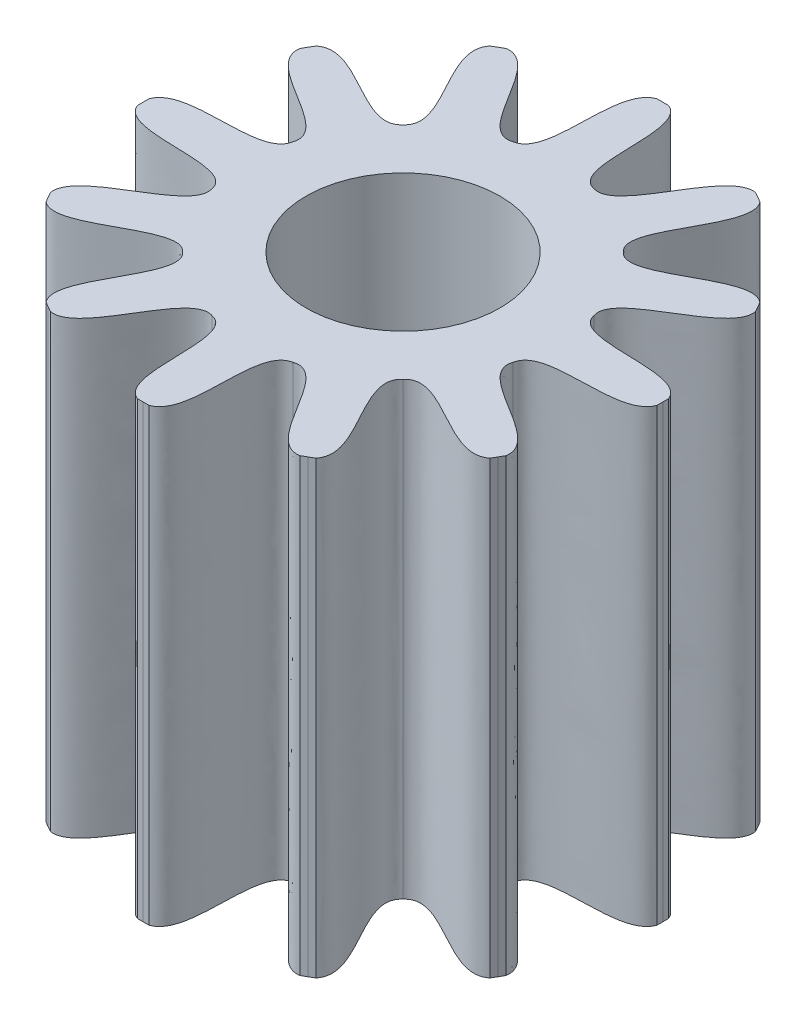
from build123d import *

# Parameters (mm, degrees)
BOSS_EXTRUDE1_12_TEETH_DEPTH = 1.3
CUT_EXTRUDE1_REACH           = 3.3
SKETCH2_R                    = 0.28


with BuildPart() as part:
    # Sketch1 → Boss-Extrude1 (12 teeth) (new body)
    with BuildSketch(Plane(origin=(0, 0, 0), x_dir=(1, 0, 0), z_dir=(0, 1, 0))):
        with BuildLine():
            Line((0, 0.75), (0.016998908, 0.749807333))
            add(Edge.make_bspline(
                [(0.016998908, 0.749807333), (0.1073915, 0.715734638), (0.02468594, 0.452106326), (0.11646857, 0.434666622)],
                knots=[0, 0, 0, 0, 1, 1, 1, 1], degree=3))
            add(Edge.make_bspline(
                [(0.36018218, 0.657851653), (0.264863552, 0.673540129), (0.204674512, 0.403878534), (0.11646857, 0.434666622)],
                knots=[0, 0, 0, 0, 1, 1, 1, 1], degree=3))
            Line((0.36018218, 0.657851653), (0.375, 0.649519053))
            Line((0.375, 0.649519053), (0.389625153, 0.640852745))
            add(Edge.make_bspline(
                [(0.389625153, 0.640852745), (0.450871086, 0.566148629), (0.247431814, 0.379192594), (0.318198052, 0.318198052)],
                knots=[0, 0, 0, 0, 1, 1, 1, 1], degree=3))
            add(Edge.make_bspline(
                [(0.640852745, 0.389625153), (0.566148629, 0.450871086), (0.379192594, 0.247431814), (0.318198052, 0.318198052)],
                knots=[0, 0, 0, 0, 1, 1, 1, 1], degree=3))
            Line((0.640852745, 0.389625153), (0.649519053, 0.375))
            Line((0.649519053, 0.375), (0.657851653, 0.36018218))
            add(Edge.make_bspline(
                [(0.657851653, 0.36018218), (0.673540129, 0.264863552), (0.403878534, 0.204674512), (0.434666622, 0.11646857)],
                knots=[0, 0, 0, 0, 1, 1, 1, 1], degree=3))
            add(Edge.make_bspline(
                [(0.749807333, 0.016998908), (0.715734638, 0.1073915), (0.452106326, 0.02468594), (0.434666622, 0.11646857)],
                knots=[0, 0, 0, 0, 1, 1, 1, 1], degree=3))
            Line((0.749807333, 0.016998908), (0.75, 0))
            Line((0.75, 0), (0.749807333, -0.016998908))
            add(Edge.make_bspline(
                [(0.749807333, -0.016998908), (0.715734638, -0.1073915), (0.452106326, -0.02468594), (0.434666622, -0.11646857)],
                knots=[0, 0, 0, 0, 1, 1, 1, 1], degree=3))
            add(Edge.make_bspline(
                [(0.657851653, -0.36018218), (0.673540129, -0.264863552), (0.403878534, -0.204674512), (0.434666622, -0.11646857)],
                knots=[0, 0, 0, 0, 1, 1, 1, 1], degree=3))
            Line((0.657851653, -0.36018218), (0.649519053, -0.375))
            Line((0.649519053, -0.375), (0.640852745, -0.389625153))
            add(Edge.make_bspline(
                [(0.640852745, -0.389625153), (0.566148629, -0.450871086), (0.379192594, -0.247431814), (0.318198052, -0.318198052)],
                knots=[0, 0, 0, 0, 1, 1, 1, 1], degree=3))
            add(Edge.make_bspline(
                [(0.389625153, -0.640852745), (0.450871086, -0.566148629), (0.247431814, -0.379192594), (0.318198052, -0.318198052)],
                knots=[0, 0, 0, 0, 1, 1, 1, 1], degree=3))
            Line((0.389625153, -0.640852745), (0.375, -0.649519053))
            Line((0.375, -0.649519053), (0.36018218, -0.657851653))
            add(Edge.make_bspline(
                [(0.36018218, -0.657851653), (0.264863552, -0.673540129), (0.204674512, -0.403878534), (0.11646857, -0.434666622)],
                knots=[0, 0, 0, 0, 1, 1, 1, 1], degree=3))
            add(Edge.make_bspline(
                [(0.016998908, -0.749807333), (0.1073915, -0.715734638), (0.02468594, -0.452106326), (0.11646857, -0.434666622)],
                knots=[0, 0, 0, 0, 1, 1, 1, 1], degree=3))
            Line((0.016998908, -0.749807333), (0, -0.75))
            Line((0, -0.75), (-0.016998908, -0.749807333))
            add(Edge.make_bspline(
                [(-0.016998908, -0.749807333), (-0.1073915, -0.715734638), (-0.02468594, -0.452106326), (-0.11646857, -0.434666622)],
                knots=[0, 0, 0, 0, 1, 1, 1, 1], degree=3))
            add(Edge.make_bspline(
                [(-0.36018218, -0.657851653), (-0.264863552, -0.673540129), (-0.204674512, -0.403878534), (-0.11646857, -0.434666622)],
                knots=[0, 0, 0, 0, 1, 1, 1, 1], degree=3))
            Line((-0.36018218, -0.657851653), (-0.375, -0.649519053))
            Line((-0.375, -0.649519053), (-0.389625153, -0.640852745))
            add(Edge.make_bspline(
                [(-0.389625153, -0.640852745), (-0.450871086, -0.566148629), (-0.247431814, -0.379192594), (-0.318198052, -0.318198052)],
                knots=[0, 0, 0, 0, 1, 1, 1, 1], degree=3))
            add(Edge.make_bspline(
                [(-0.640852745, -0.389625153), (-0.566148629, -0.450871086), (-0.379192594, -0.247431814), (-0.318198052, -0.318198052)],
                knots=[0, 0, 0, 0, 1, 1, 1, 1], degree=3))
            Line((-0.640852745, -0.389625153), (-0.649519053, -0.375))
            Line((-0.649519053, -0.375), (-0.657851653, -0.36018218))
            add(Edge.make_bspline(
                [(-0.657851653, -0.36018218), (-0.673540129, -0.264863552), (-0.403878534, -0.204674512), (-0.434666622, -0.11646857)],
                knots=[0, 0, 0, 0, 1, 1, 1, 1], degree=3))
            add(Edge.make_bspline(
                [(-0.749807333, -0.016998908), (-0.715734638, -0.1073915), (-0.452106326, -0.02468594), (-0.434666622, -0.11646857)],
                knots=[0, 0, 0, 0, 1, 1, 1, 1], degree=3))
            Line((-0.749807333, -0.016998908), (-0.75, 0))
            Line((-0.75, 0), (-0.749807333, 0.016998908))
            add(Edge.make_bspline(
                [(-0.749807333, 0.016998908), (-0.715734638, 0.1073915), (-0.452106326, 0.02468594), (-0.434666622, 0.11646857)],
                knots=[0, 0, 0, 0, 1, 1, 1, 1], degree=3))
            add(Edge.make_bspline(
                [(-0.657851653, 0.36018218), (-0.673540129, 0.264863552), (-0.403878534, 0.204674512), (-0.434666622, 0.11646857)],
                knots=[0, 0, 0, 0, 1, 1, 1, 1], degree=3))
            Line((-0.657851653, 0.36018218), (-0.649519053, 0.375))
            Line((-0.649519053, 0.375), (-0.640852745, 0.389625153))
            add(Edge.make_bspline(
                [(-0.640852745, 0.389625153), (-0.566148629, 0.450871086), (-0.379192594, 0.247431814), (-0.318198052, 0.318198052)],
                knots=[0, 0, 0, 0, 1, 1, 1, 1], degree=3))
            add(Edge.make_bspline(
                [(-0.389625153, 0.640852745), (-0.450871086, 0.566148629), (-0.247431814, 0.379192594), (-0.318198052, 0.318198052)],
                knots=[0, 0, 0, 0, 1, 1, 1, 1], degree=3))
            Line((-0.389625153, 0.640852745), (-0.375, 0.649519053))
            Line((-0.375, 0.649519053), (-0.36018218, 0.657851653))
            add(Edge.make_bspline(
                [(-0.36018218, 0.657851653), (-0.264863552, 0.673540129), (-0.204674512, 0.403878534), (-0.11646857, 0.434666622)],
                knots=[0, 0, 0, 0, 1, 1, 1, 1], degree=3))
            add(Edge.make_bspline(
                [(-0.016998908, 0.749807333), (-0.1073915, 0.715734638), (-0.02468594, 0.452106326), (-0.11646857, 0.434666622)],
                knots=[0, 0, 0, 0, 1, 1, 1, 1], degree=3))
            Line((-0.016998908, 0.749807333), (0, 0.75))
        make_face()
    extrude(amount=BOSS_EXTRUDE1_12_TEETH_DEPTH)

    # Sketch2 → Cut-Extrude1 (cut, up to next)
    with BuildSketch(Plane(origin=(0, 0, 0), x_dir=(1, 0, 0), z_dir=(0, 1, 0)), mode=Mode.PRIVATE) as cut_extrude1_sk1:
        Circle(SKETCH2_R)
    cut_extrude1_tool1 = extrude(cut_extrude1_sk1.sketch, amount=CUT_EXTRUDE1_REACH, mode=Mode.PRIVATE) & part.part
    add(cut_extrude1_tool1.solids().sort_by_distance((0, 0, 0))[0], mode=Mode.SUBTRACT)


solid = part.part
